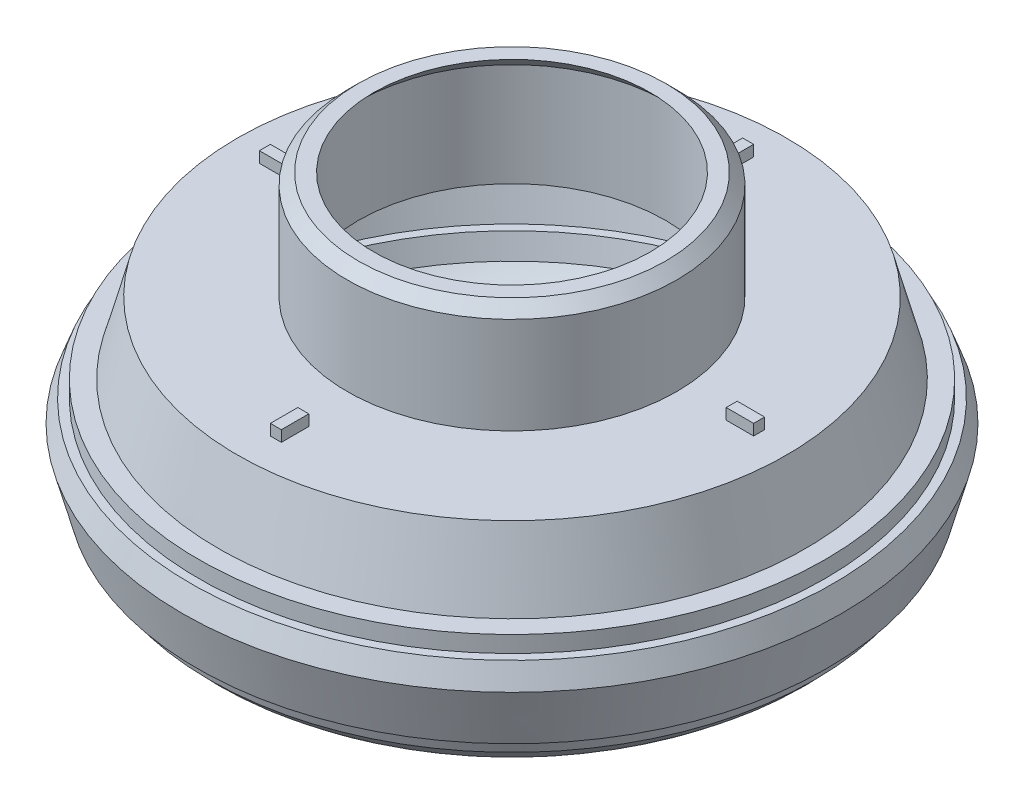
from build123d import *

# Parameters (mm, degrees)
SKETCH2_R           = 15
BOSS_EXTRUDE1_DEPTH = 9.8
CHAMFER1_SIZE       = 1
SHELL1_T            = -1
SKETCH7_W           = 2.5
SKETCH7_H           = 1
BOSS_EXTRUDE5_DEPTH = 1
CIRPATTERN1_COUNT   = 4


with BuildPart() as part:
    # Sketch1 → Revolve2 (revolve)
    with BuildSketch(Plane.XY):
        with BuildLine():
            Line((-25, 10), (-26.741669751, 3.5))
            Line((-26.741669751, 3.5), (-28.5, 3.5))
            Line((-28.5, 3.5), (-28.5, 2))
            Line((-28.5, 2), (-29.258330249, 2))
            Line((-29.258330249, 2), (-30, 0))
            Line((-30, 0), (-28.660254038, -5))
            Line((-28.660254038, -5), (-27.901923789, -5))
            Line((-27.901923789, -5), (-27.5, -6.5))
            ThreePointArc((-27.5, -6.5), (-24.083958056, -9.082951062), (-19.900657923, -10))
            Line((-19.900657923, -10), (0, -10))
            Line((0, -10), (0, 10))
            Line((0, 10), (-25, 10))
        make_face()
    revolve(axis=Axis((0, 614.019679743, 0), (0, -1, 0)))

    # Sketch2 → Boss-Extrude1 (add)
    with BuildSketch(Plane(origin=(0, 10, 0), x_dir=(1, 0, 0), z_dir=(0, 1, 0))):
        with Locations(Location((0, 0, 0), (0, 0, 180))):
            Circle(SKETCH2_R)
    extrude(amount=BOSS_EXTRUDE1_DEPTH)

    # Chamfer1
    chamfer1_edges = [part.edges().sort_by_distance(p)[0] for p in [
        (15, 19.8, 0),
    ]]
    chamfer(chamfer1_edges, length=CHAMFER1_SIZE)

    # Shell1
    shell1_openings = [part.faces().sort_by_distance(p)[0] for p in [
        (0, 19.8, 0),
    ]]
    offset(amount=SHELL1_T, openings=shell1_openings, kind=Kind.INTERSECTION)

    # Sketch7 → Boss-Extrude5 (add)
    with BuildSketch(Plane(origin=(0, 10, 0), x_dir=(1, 0, 0), z_dir=(0, 1, 0))):
        with Locations((-20.75, -0.5)):
            Rectangle(SKETCH7_W, SKETCH7_H)
    boss_extrude5 = extrude(amount=BOSS_EXTRUDE5_DEPTH)

    # CirPattern1: Boss-Extrude5 ×4 about axis
    cirpattern1_axis = Axis((0, 0, 0), (0, 1, 0))
    for i in range(1, CIRPATTERN1_COUNT):
        add(boss_extrude5.rotate(cirpattern1_axis, i * 360 / CIRPATTERN1_COUNT))


solid = part.part
